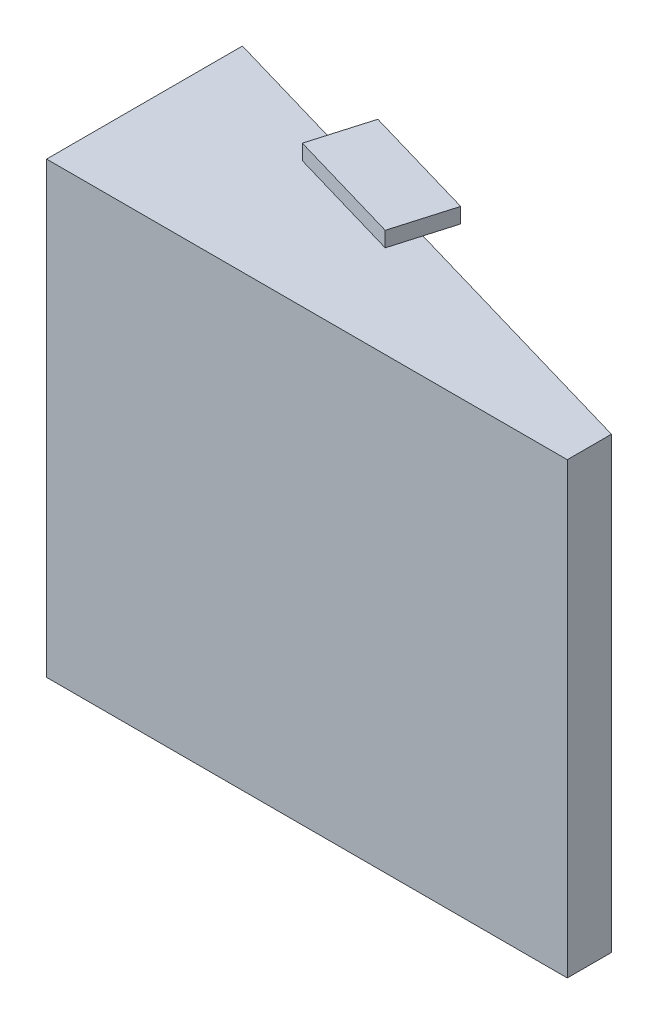
from build123d import *

# Parameters (mm, degrees)
BOSS_EXTRUDE1_DEPTH = 29.5
SKETCH2_W           = 20.5
SKETCH2_H           = 26.5
CUT_EXTRUDE1_DEPTH  = 5.5
CUT_EXTRUDE2_REACH  = 36.22
SKETCH3_W           = 7.420012267
SKETCH3_H           = 23.5
SKETCH4_R           = 1.15
BOSS_EXTRUDE2_DEPTH = 2
BOSS_EXTRUDE3_DEPTH = 1
BOSS_EXTRUDE4_DEPTH = 1


with BuildPart() as part:
    # Sketch1 → Boss-Extrude1 (new body)
    with BuildSketch(Plane(origin=(0, 0, 0), x_dir=(1, 0, 0), z_dir=(0, 1, 0))):
        Polygon((-25.843422974, -5.060047824), (-25.843422974, 4.909964443), (8.376577026, -5.060047824), (8.376577026, -7.960047824), (-25.843422974, -7.960047824), align=None)
    extrude(amount=BOSS_EXTRUDE1_DEPTH)

    # Sketch2 → Cut-Extrude1 (cut)
    with BuildSketch(Plane(origin=(-0.703485348, 0, 2.414567601), x_dir=(-0.960081566, 0, -0.279720193), z_dir=(0.279720193, 0, -0.960081566))):
        with Locations((11.935210206, 14.75)):
            Rectangle(SKETCH2_W, SKETCH2_H)
    extrude(amount=-CUT_EXTRUDE1_DEPTH, mode=Mode.SUBTRACT)

    # Cut-Extrude2: up to this face of the body (flat: up to its plane)
    cut_extrude2_end = Plane(part.part.faces().sort_by_distance((-22.772327239, 14.75, -1.150859365))[0])
    # Sketch3 → Cut-Extrude2 (cut, up to the picked face)
    with BuildSketch(Plane.ZY.offset(25.843422974), mode=Mode.PRIVATE) as cut_extrude2_sk1:
        with Locations((-1.19995831, 14.75)):
            Rectangle(SKETCH3_W, SKETCH3_H)
    cut_extrude2_tool1 = split(extrude(cut_extrude2_sk1.sketch, amount=-CUT_EXTRUDE2_REACH, mode=Mode.PRIVATE), bisect_by=cut_extrude2_end, keep=Keep.BOTH, mode=Mode.PRIVATE)
    add(cut_extrude2_tool1.solids().sort_by_distance((-25.843423, 14.75, -1.199958))[0], mode=Mode.SUBTRACT)

    # Sketch4 → Boss-Extrude2 (add)
    with BuildSketch(Plane(origin=(-2.241946407, 0, 7.695016215), x_dir=(-0.960081566, 0, -0.279720193), z_dir=(0.279720193, 0, -0.960081566))):
        with Locations((19.685210206, 25.5)):
            Circle(SKETCH4_R)
        with Locations((19.685210206, 3.9)):
            Circle(SKETCH4_R)
        with Locations((4.485210206, 3.9)):
            Circle(SKETCH4_R)
        with Locations((4.485210206, 25.5)):
            Circle(SKETCH4_R)
    extrude(amount=BOSS_EXTRUDE2_DEPTH)

    # Sketch5 → Boss-Extrude3 (add)
    with BuildSketch(Plane(origin=(0, 0, 0), x_dir=(-1, 0, 0), z_dir=(0, -1, 0))):
        Polygon((9.662770444, -1.887432229), (17.343422974, 0.350329313), (16.224542204, 4.190655577), (8.543889674, 1.952894036), align=None)
    extrude(amount=BOSS_EXTRUDE3_DEPTH)

    # Sketch6 → Boss-Extrude4 (add)
    with BuildSketch(Plane(origin=(0, 29.5, 0), x_dir=(1, 0, 0), z_dir=(0, 1, 0))):
        Polygon((-16.224542204, 4.190655577), (-8.543889674, 1.952894036), (-9.662770444, -1.887432229), (-17.343422974, 0.350329313), align=None)
    extrude(amount=BOSS_EXTRUDE4_DEPTH)


solid = part.part
